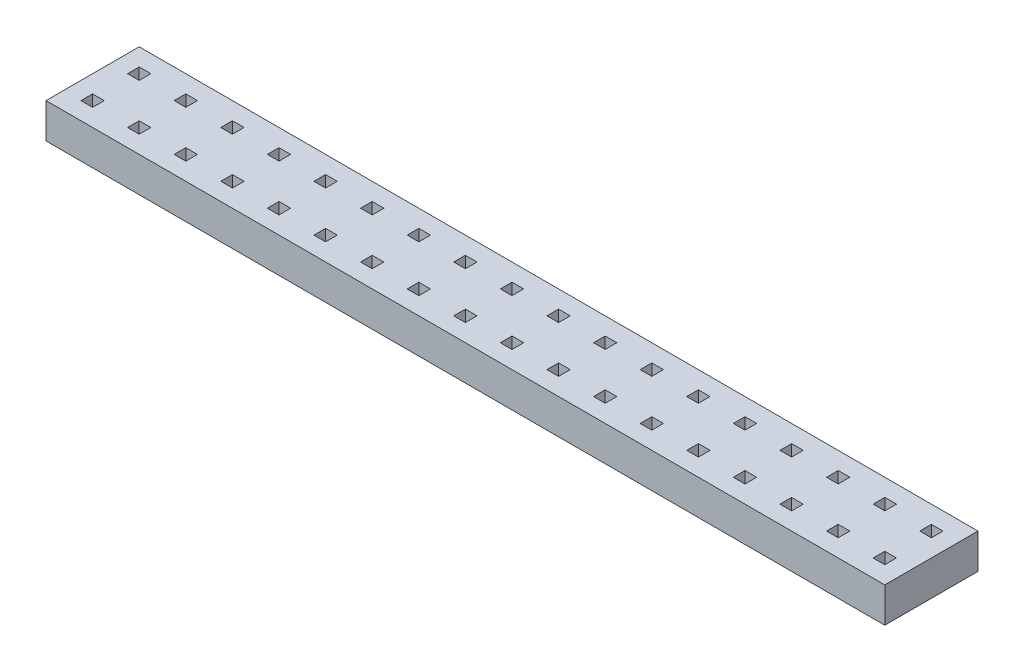
from build123d import *

# Parameters (mm, degrees)
SKETCH1_W           = 36
SKETCH1_H           = 4
BOSS_EXTRUDE1_DEPTH = 1.5
SKETCH2_W           = 0.5
SKETCH2_H           = 0.5
CUT_EXTRUDE1_DEPTH  = 2


with BuildPart() as part:
    # Sketch1 → Boss-Extrude1 (new body)
    with BuildSketch(Plane(origin=(0, 0, 0), x_dir=(1, 0, 0), z_dir=(0, 1, 0))):
        with Locations((18, 2)):
            Rectangle(SKETCH1_W, SKETCH1_H)
    extrude(amount=BOSS_EXTRUDE1_DEPTH)

    # Sketch2 → Cut-Extrude1 (cut)
    with BuildSketch(Plane(origin=(0, 1.5, 0), x_dir=(1, 0, 0), z_dir=(0, 1, 0))):
        with Locations((3, 3)):
            Rectangle(SKETCH2_W, SKETCH2_H)
        with Locations((1, 3)):
            Rectangle(SKETCH2_W, SKETCH2_H)
        with Locations((5, 3)):
            Rectangle(SKETCH2_W, SKETCH2_H)
        with Locations((7, 3)):
            Rectangle(SKETCH2_W, SKETCH2_H)
        with Locations((9, 3)):
            Rectangle(SKETCH2_W, SKETCH2_H)
        with Locations((11, 3)):
            Rectangle(SKETCH2_W, SKETCH2_H)
        with Locations((13, 3)):
            Rectangle(SKETCH2_W, SKETCH2_H)
        with Locations((15, 3)):
            Rectangle(SKETCH2_W, SKETCH2_H)
        with Locations((17, 3)):
            Rectangle(SKETCH2_W, SKETCH2_H)
        with Locations((19, 3)):
            Rectangle(SKETCH2_W, SKETCH2_H)
        with Locations((21, 3)):
            Rectangle(SKETCH2_W, SKETCH2_H)
        with Locations((23, 3)):
            Rectangle(SKETCH2_W, SKETCH2_H)
        with Locations((25, 3)):
            Rectangle(SKETCH2_W, SKETCH2_H)
        with Locations((27, 3)):
            Rectangle(SKETCH2_W, SKETCH2_H)
        with Locations((29, 3)):
            Rectangle(SKETCH2_W, SKETCH2_H)
        with Locations((31, 3)):
            Rectangle(SKETCH2_W, SKETCH2_H)
        with Locations((33, 3)):
            Rectangle(SKETCH2_W, SKETCH2_H)
        with Locations((35, 3)):
            Rectangle(SKETCH2_W, SKETCH2_H)
        with Locations((1, 1)):
            Rectangle(SKETCH2_W, SKETCH2_H)
        with Locations((3, 1)):
            Rectangle(SKETCH2_W, SKETCH2_H)
        with Locations((5, 1)):
            Rectangle(SKETCH2_W, SKETCH2_H)
        with Locations((7, 1)):
            Rectangle(SKETCH2_W, SKETCH2_H)
        with Locations((9, 1)):
            Rectangle(SKETCH2_W, SKETCH2_H)
        with Locations((11, 1)):
            Rectangle(SKETCH2_W, SKETCH2_H)
        with Locations((13, 1)):
            Rectangle(SKETCH2_W, SKETCH2_H)
        with Locations((15, 1)):
            Rectangle(SKETCH2_W, SKETCH2_H)
        with Locations((17, 1)):
            Rectangle(SKETCH2_W, SKETCH2_H)
        with Locations((19, 1)):
            Rectangle(SKETCH2_W, SKETCH2_H)
        with Locations((21, 1)):
            Rectangle(SKETCH2_W, SKETCH2_H)
        with Locations((23, 1)):
            Rectangle(SKETCH2_W, SKETCH2_H)
        with Locations((25, 1)):
            Rectangle(SKETCH2_W, SKETCH2_H)
        with Locations((27, 1)):
            Rectangle(SKETCH2_W, SKETCH2_H)
        with Locations((29, 1)):
            Rectangle(SKETCH2_W, SKETCH2_H)
        with Locations((31, 1)):
            Rectangle(SKETCH2_W, SKETCH2_H)
        with Locations((33, 1)):
            Rectangle(SKETCH2_W, SKETCH2_H)
        with Locations((35, 1)):
            Rectangle(SKETCH2_W, SKETCH2_H)
    extrude(amount=-CUT_EXTRUDE1_DEPTH, mode=Mode.SUBTRACT)


solid = part.part
